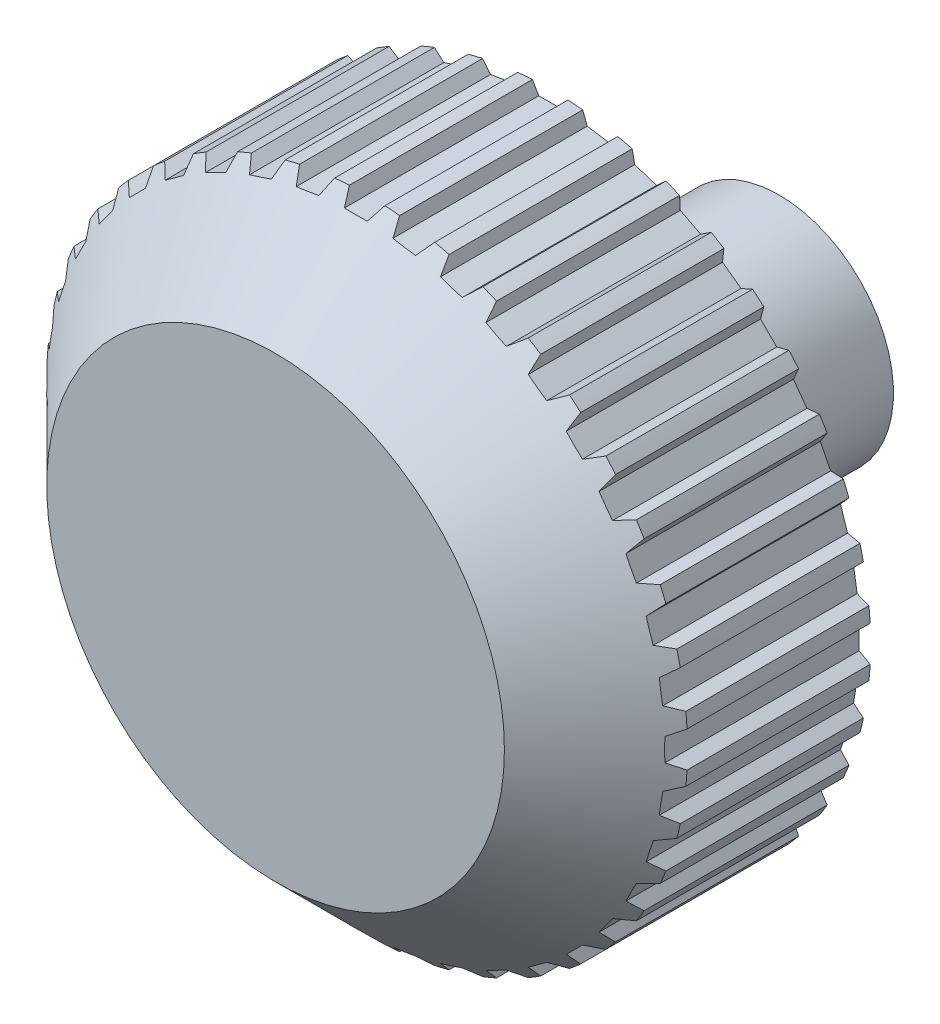
from build123d import *

# Parameters (mm, degrees)
ESQUISSE1_R                  = 14
BOSS_EXTRU_1_DEPTH           = 12
ENL_V_MAT_EXTRU_1_DEPTH      = 13
R_P_TITION_CIRCULAIRE1_COUNT = 40
ESQUISSE6_R                  = 12
ENL_V_MAT_EXTRU_2_DEPTH      = 6
ESQUISSE7_R                  = 5
BOSS_EXTRU_2_DEPTH           = 16
ESQUISSE8_R                  = 3.1
ENL_V_MAT_EXTRU_3_DEPTH      = 10
BOSS_EXTRU_3_DEPTH           = 6


with BuildPart() as part:
    # Esquisse1 → Boss.-Extru.1 (new body)
    with BuildSketch(Plane.XY):
        Circle(ESQUISSE1_R)
    extrude(amount=BOSS_EXTRU_1_DEPTH)

    # Esquisse2 → Enlèv. mat.-Extru.1 (cut, through all)
    with BuildSketch(Plane.XY.offset(12)):
        Polygon((-1.654700538, 15.5), (-0.5, 13.5), (0.5, 13.5), (1.654700538, 15.5), align=None)
    enl_v_mat_extru_1 = extrude(amount=-ENL_V_MAT_EXTRU_1_DEPTH, mode=Mode.SUBTRACT)

    # Répétition circulaire1: Enlèv. mat.-Extru.1 ×40 about axis
    r_p_tition_circulaire1_axis = Axis((0, 0, 0), (0, 0, 1))
    for i in range(1, R_P_TITION_CIRCULAIRE1_COUNT):
        add(enl_v_mat_extru_1.rotate(r_p_tition_circulaire1_axis, i * 360 / R_P_TITION_CIRCULAIRE1_COUNT), mode=Mode.SUBTRACT)

    # Esquisse5 → Enlèvement de matière-Révolution1 (revolve, cut)
    with BuildSketch(Plane(origin=(0, 0, 0), x_dir=(1, 0, 0), z_dir=(0, 1, 0))):
        Polygon((10, -12), (14, -8), (14, -12), align=None)
    revolve(axis=Axis((0, 0, 18.097465992), (0, 0, -1)), mode=Mode.SUBTRACT)

    # Esquisse6 → Enlèv. mat.-Extru.2 (cut)
    with BuildSketch(Plane(origin=(0, 0, 0), x_dir=(-1, 0, 0), z_dir=(0, 0, -1))):
        Circle(ESQUISSE6_R)
    extrude(amount=-ENL_V_MAT_EXTRU_2_DEPTH, mode=Mode.SUBTRACT)

    # Esquisse7 → Boss.-Extru.2 (add)
    with BuildSketch(Plane(origin=(0, 0, 6), x_dir=(-1, 0, 0), z_dir=(0, 0, -1))):
        Circle(ESQUISSE7_R)
    extrude(amount=BOSS_EXTRU_2_DEPTH)

    # Esquisse8 → Enlèv. mat.-Extru.3 (cut)
    with BuildSketch(Plane(origin=(0, 0, -10), x_dir=(-1, 0, 0), z_dir=(0, 0, -1))):
        Circle(ESQUISSE8_R)
    extrude(amount=-ENL_V_MAT_EXTRU_3_DEPTH, mode=Mode.SUBTRACT)

    # Esquisse9 → Boss.-Extru.3 (add)
    with BuildSketch(Plane(origin=(0, 0, 0), x_dir=(-1, 0, 0), z_dir=(0, 0, -1))):
        with BuildLine():
            Line((-1.5, -2.712931993), (-1.5, 2.712931993))
            ThreePointArc((-1.5, 2.712931993), (-3.1, 0), (-1.5, -2.712931993))
        make_face()
    extrude(amount=BOSS_EXTRU_3_DEPTH)


solid = part.part
